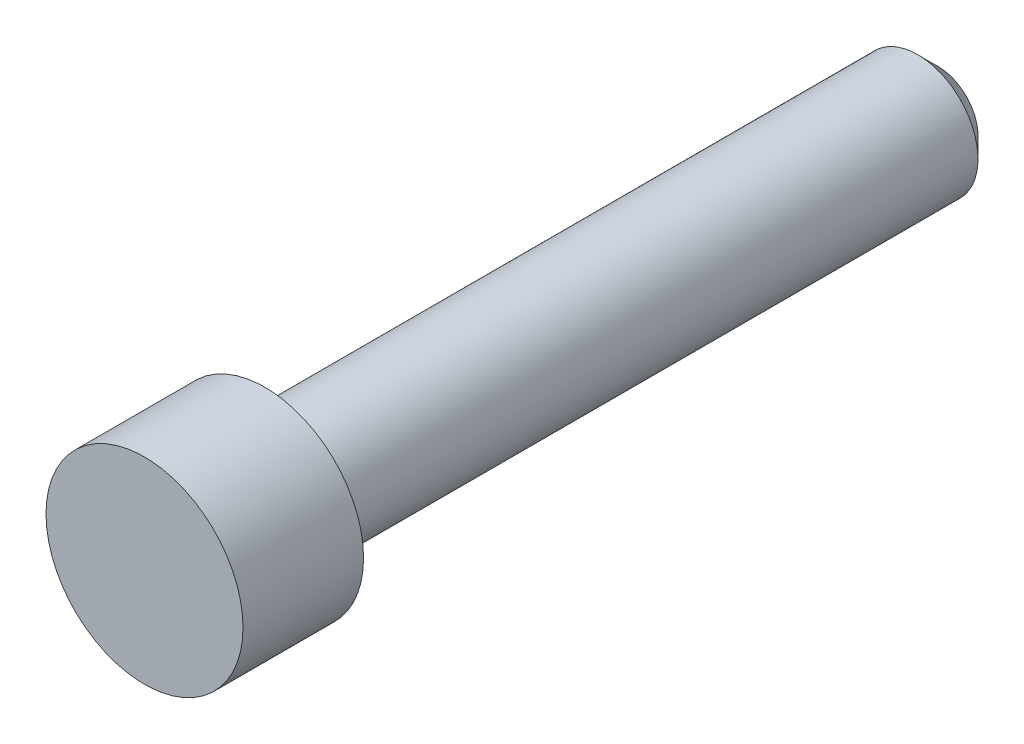
from build123d import *


with BuildPart() as part:
    # Sketch2 → Revolve1 (revolve)
    with BuildSketch(Plane(origin=(0, 0, 0), x_dir=(0, 0, -1), z_dir=(1, 0, 0))):
        Polygon((9.3599, 0.94615), (8.88365, 1.4224), (-6.5151, 1.4224), (-6.5151, 2.3241), (-9.3599, 2.3241), (-9.3599, 0), (9.3599, 0), align=None)
    revolve(axis=Axis((0, 0, -9.3599), (0, 0, 1)))


solid = part.part
